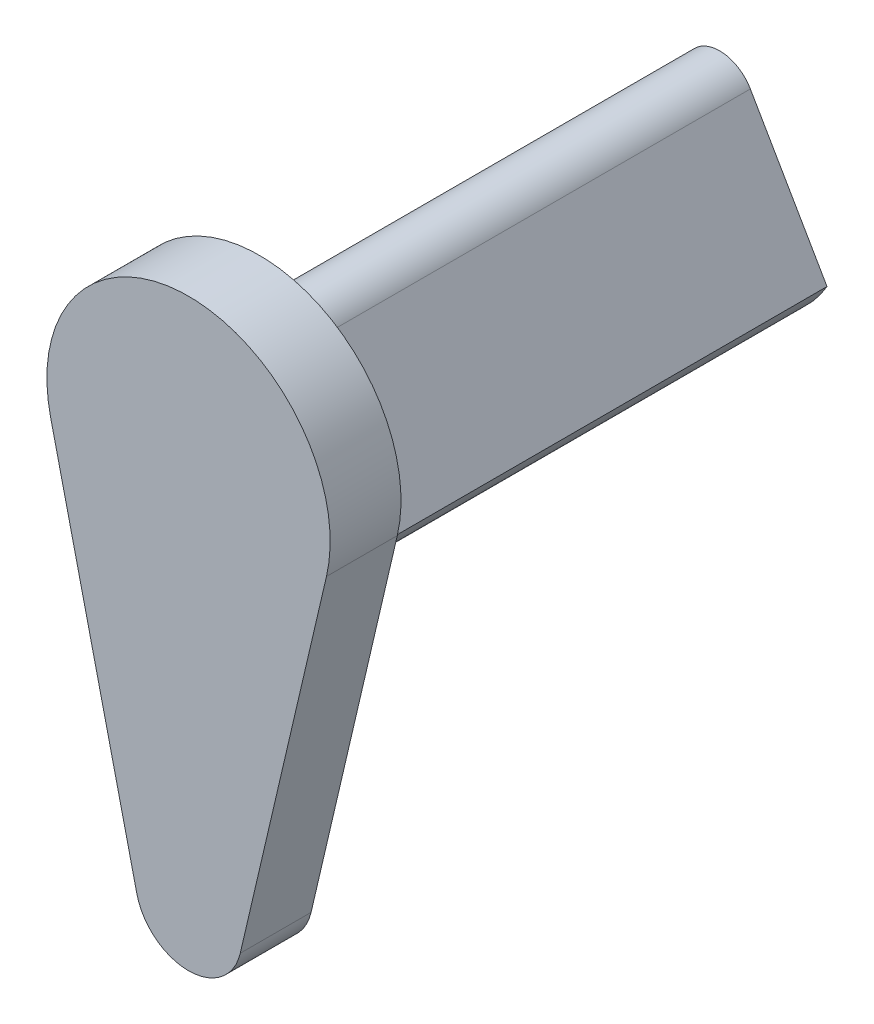
from build123d import *

# Parameters (mm, degrees)
SKETCH_1_R          = 3.5
EXTRUDE_1_DEPTH     = 13
EXTRUDE_2_DEPTH     = 2
CUT_EXTRUDE_1_DEPTH = 13
SKETCH_4_R          = 1.25
CUT_EXTRUDE_2_DEPTH = 8
FILLET_1_R          = 1


with BuildPart() as part:
    # 草图1 → 凸台-拉伸1 (new body)
    with BuildSketch(Plane.XY):
        Circle(SKETCH_1_R)
    extrude(amount=EXTRUDE_1_DEPTH)

    # 草图2 → 凸台-拉伸2 (add)
    with BuildSketch(Plane.XY.offset(13)):
        with BuildLine():
            Line((-3.895324597, -0.909090909), (-1.460746724, -11.340909091))
            ThreePointArc((-1.460746724, -11.340909091), (0, -12.5), (1.460746724, -11.340909091))
            Line((1.460746724, -11.340909091), (3.895324597, -0.909090909))
            ThreePointArc((3.895324597, -0.909090909), (0, 4), (-3.895324597, -0.909090909))
        make_face()
    extrude(amount=EXTRUDE_2_DEPTH)

    # 草图3 → 切除-拉伸1 (cut)
    with BuildSketch(Plane(origin=(0, 0, 0), x_dir=(-1, 0, 0), z_dir=(0, 0, -1))):
        Polygon((0, 3.5), (-3.031088913, -1.75), (-6.759949263, -1.75), (0, 7.742275781), (6.759949263, -1.75), (3.031088913, -1.75), align=None)
    extrude(amount=-CUT_EXTRUDE_1_DEPTH, mode=Mode.SUBTRACT)

    # 草图4 → 切除-拉伸2 (cut)
    with BuildSketch(Plane(origin=(0, 0, 0), x_dir=(-1, 0, 0), z_dir=(0, 0, -1))):
        Circle(SKETCH_4_R)
    extrude(amount=-CUT_EXTRUDE_2_DEPTH, mode=Mode.SUBTRACT)

    # 圆角1
    fillet_1_edges = [part.edges().sort_by_distance(p)[0] for p in [
        (0, 3.5, 6.5),
    ]]
    fillet(fillet_1_edges, radius=FILLET_1_R)


solid = part.part
